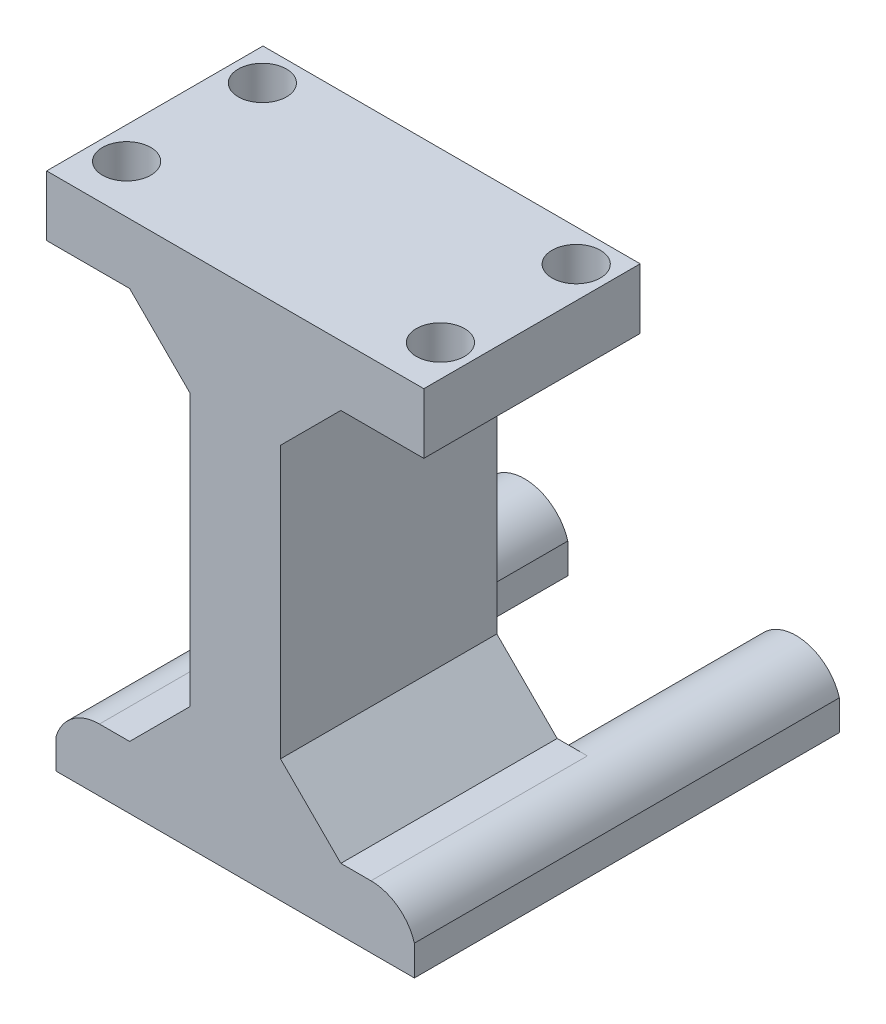
from build123d import *

# Parameters (mm, degrees)
ESTRUSIONE_ESTRUSIONE1_DEPTH   = 105
ESTRUSIONE_ESTRUSIONE1_2_DEPTH = 105
SCHIZZO2_W                     = 28.749445424
SCHIZZO2_H                     = 105
ESTRUSIONE_ESTRUSIONE2_DEPTH   = 10
ESTRUSIONE_ESTRUSIONE3_DEPTH   = 35.85
SCHIZZO4_W                     = 30
SCHIZZO4_H                     = 71.7
ESTRUSIONE_ESTRUSIONE4_DEPTH   = 130
SCHIZZO5_W                     = 125.014718626
SCHIZZO5_H                     = 71.7
ESTRUSIONE_ESTRUSIONE5_DEPTH   = 20
SMUSSO1_SIZE                   = 20


with BuildPart() as part:
    # Schizzo1 → Estrusione-Estrusione1 (new body)
    with BuildSketch(Plane.XY):
        with BuildLine():
            ThreePointArc((14.374722712, 4.285714286), (0, 15), (-14.374722712, 4.285714286))
            Line((-14.374722712, 4.285714286), (14.374722712, 4.285714286))
        make_face()
    extrude(amount=-ESTRUSIONE_ESTRUSIONE1_DEPTH)



with BuildPart() as body_2:
    # Schizzo1 → Estrusione-Estrusione1 2 (new body)
    with BuildSketch(Plane.XY):
        with BuildLine():
            Line((75.625277288, 4.285714286), (104.374722712, 4.285714286))
            ThreePointArc((104.374722712, 4.285714286), (90, 15), (75.625277288, 4.285714286))
        make_face()
    extrude(amount=-ESTRUSIONE_ESTRUSIONE1_2_DEPTH)


with BuildPart() as part_1:
    add(part.part)

    add(body_2.part)  # Estrusione-Estrusione2 merges body 2
    # Schizzo2 → Estrusione-Estrusione2 (add)
    with BuildSketch(Plane.XZ.offset(-4.285714286)):
        with Locations((0, -52.5)):
            Rectangle(SCHIZZO2_W, SCHIZZO2_H)
        with Locations((90, -52.5)):
            Rectangle(SCHIZZO2_W, SCHIZZO2_H)
    extrude(amount=ESTRUSIONE_ESTRUSIONE2_DEPTH)

    # Schizzo3 → Estrusione-Estrusione3 (add, symmetric)
    with BuildSketch(Plane.XY):
        with BuildLine():
            Line((-14.374722712, -5.714285714), (104.374722712, -5.714285714))
            Line((104.374722712, -5.714285714), (104.374722712, 4.285714286))
            ThreePointArc((104.374722712, 4.285714286), (98.96421457, 12.026755886), (90, 15))
            Line((90, 15), (0, 15))
            ThreePointArc((0, 15), (-8.96421457, 12.026755886), (-14.374722712, 4.285714286))
            Line((-14.374722712, 4.285714286), (-14.374722712, -5.714285714))
        make_face()
    extrude(amount=ESTRUSIONE_ESTRUSIONE3_DEPTH, both=True)

    # Schizzo4 → Estrusione-Estrusione4 (add)
    with BuildSketch(Plane(origin=(0, 15, 0), x_dir=(1, 0, 0), z_dir=(0, 1, 0))):
        with Locations((45, 0)):
            Rectangle(SCHIZZO4_W, SCHIZZO4_H)
    extrude(amount=ESTRUSIONE_ESTRUSIONE4_DEPTH)

    # Schizzo5 → Estrusione-Estrusione5 (add)
    with BuildSketch(Plane(origin=(0, 145, -145), x_dir=(1, 0, 0), z_dir=(0, -1, 0))):
        with Locations((45, 145)):
            Rectangle(SCHIZZO5_W, SCHIZZO5_H)
        with BuildLine():
            ThreePointArc((97, 156.85), (105, 164.85), (97, 172.85))
            ThreePointArc((97, 172.85), (89, 164.85), (97, 156.85))
        make_face(mode=Mode.SUBTRACT)
        with BuildLine():
            ThreePointArc((97, 127.85), (89, 119.85), (97, 111.85))
            ThreePointArc((97, 111.85), (105, 119.85), (97, 127.85))
        make_face(mode=Mode.SUBTRACT)
        with BuildLine():
            ThreePointArc((-7, 127.85), (-15, 119.85), (-7, 111.85))
            ThreePointArc((-7, 111.85), (1, 119.85), (-7, 127.85))
        make_face(mode=Mode.SUBTRACT)
        with BuildLine():
            ThreePointArc((-7, 156.85), (1, 164.85), (-7, 172.85))
            ThreePointArc((-7, 172.85), (-15, 164.85), (-7, 156.85))
        make_face(mode=Mode.SUBTRACT)
    extrude(amount=-ESTRUSIONE_ESTRUSIONE5_DEPTH)

    # Smusso1
    smusso1_edges = [part_1.edges().sort_by_distance(p)[0] for p in [
        (30, 15, 0),
        (60, 15, 0),
        (30, 145, 0),
        (60, 145, 0),
    ]]
    chamfer(smusso1_edges, length=SMUSSO1_SIZE)


solid = part_1.part
